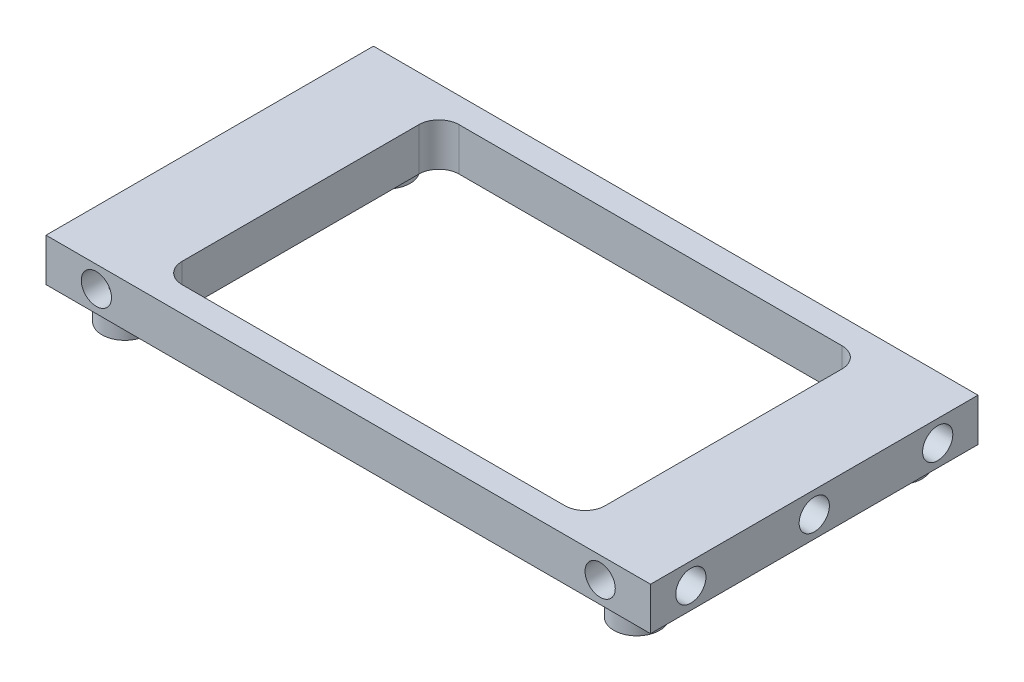
from build123d import *

# Parameters (mm, degrees)
SKETCH1_W                      = 65
SKETCH1_H                      = 8.5
BOSS_EXTRUDE1_DEPTH            = 120
F_6_0MM_DOWEL_HOLE1_AT_2_COUNT = 2
F_6_0MM_DOWEL_HOLE1_AT_2_PITCH = 24.5
F_6_0MM_DOWEL_HOLE1_AT_3_COUNT = 2
F_6_0MM_DOWEL_HOLE1_AT_3_PITCH = 49
F_6_0MM_DOWEL_HOLE2_AT_2_COUNT = 2
F_6_0MM_DOWEL_HOLE2_AT_2_PITCH = 100
CUT_EXTRUDE1_DEPTH             = 9.5
F_3_0MM_DOWEL_HOLE1_D          = 3.5
CUT_EXTRUDE2_DEPTH             = 9.5
FILLET1_R                      = 6
BOSS_EXTRUDE2_DEPTH            = 5
SKETCH12_R                     = 2.55
CUT_EXTRUDE3_DEPTH             = 1.7
CHAMFER1_SIZE                  = 1.5
SKETCH13_W                     = 84
SKETCH13_H                     = 55
CUT_EXTRUDE4_DEPTH             = 9.5
FILLET2_R                      = 4


with BuildPart() as part:
    # Sketch1 → Boss-Extrude1 (new body)
    with BuildSketch(Plane(origin=(0, 0, 0), x_dir=(0, 0, -1), z_dir=(1, 0, 0))):
        Rectangle(SKETCH1_W, SKETCH1_H)
    extrude(amount=BOSS_EXTRUDE1_DEPTH)

    # Sketch3 → Ø6.0mm Dowel Hole1 (revolve, cut)
    with BuildSketch(Plane(origin=(120, 0, 24.5), x_dir=(0, 0, -1), z_dir=(0, 1, 0))):
        Polygon((0, 0), (0, 11.802582), (3, 10), (3, 0), align=None)
    f_6_0mm_dowel_hole1 = revolve(axis=Axis((126.35, 0, 24.5), (-1, 0, 0)), mode=Mode.SUBTRACT)

    # Ø6.0mm Dowel Hole1 at 2: Ø6.0mm Dowel Hole1 ×2
    with Locations(*[(0, 0, -i * F_6_0MM_DOWEL_HOLE1_AT_2_PITCH) for i in range(1, F_6_0MM_DOWEL_HOLE1_AT_2_COUNT)]):
        add(f_6_0mm_dowel_hole1, mode=Mode.SUBTRACT)

    # Ø6.0mm Dowel Hole1 at 3: Ø6.0mm Dowel Hole1 ×2
    with Locations(*[(0, 0, -i * F_6_0MM_DOWEL_HOLE1_AT_3_PITCH) for i in range(1, F_6_0MM_DOWEL_HOLE1_AT_3_COUNT)]):
        add(f_6_0mm_dowel_hole1, mode=Mode.SUBTRACT)

    # Mirror1: Ø6.0mm Dowel Hole1 across plane
    add(f_6_0mm_dowel_hole1.mirror(Plane(origin=(60, 0, 0), x_dir=(0, 0, 1), z_dir=(1, 0, 0))), mode=Mode.SUBTRACT)

    # Mirror1 copy 1 sketch → Mirror1 copy 1 (revolve, cut)
    with BuildSketch(Plane(origin=(0, 0, 0), x_dir=(0, 0, -1), z_dir=(0, 1, 0))):
        Polygon((0, 0), (0, -11.802582), (3, -10), (3, 0), align=None)
    revolve(axis=Axis((-6.35, 0, 0), (-1, 0, 0)), mode=Mode.SUBTRACT)

    # Mirror1 copy 2 sketch → Mirror1 copy 2 (revolve, cut)
    with BuildSketch(Plane(origin=(0, 0, -24.5), x_dir=(0, 0, -1), z_dir=(0, 1, 0))):
        Polygon((0, 0), (0, -11.802582), (3, -10), (3, 0), align=None)
    revolve(axis=Axis((-6.35, 0, -24.5), (-1, 0, 0)), mode=Mode.SUBTRACT)

    # Sketch5 → Ø6.0mm Dowel Hole2 (revolve, cut)
    with BuildSketch(Plane(origin=(110, 0, -32.5), x_dir=(0, 1, 0), z_dir=(1, 0, 0))):
        Polygon((0, 0), (0, 9.802582), (3, 8), (3, 0), align=None)
    f_6_0mm_dowel_hole2 = revolve(axis=Axis((110, 0, -38.85), (0, 0, 1)), mode=Mode.SUBTRACT)

    # Ø6.0mm Dowel Hole2 at 2: Ø6.0mm Dowel Hole2 ×2
    with Locations(*[(-i * F_6_0MM_DOWEL_HOLE2_AT_2_PITCH, 0, 0) for i in range(1, F_6_0MM_DOWEL_HOLE2_AT_2_COUNT)]):
        add(f_6_0mm_dowel_hole2, mode=Mode.SUBTRACT)

    # Mirror2: Ø6.0mm Dowel Hole2 across plane
    add(f_6_0mm_dowel_hole2.mirror(Plane.XY), mode=Mode.SUBTRACT)

    # Mirror2 copy 1 sketch → Mirror2 copy 1 (revolve, cut)
    with BuildSketch(Plane(origin=(10, 0, 32.5), x_dir=(0, 1, 0), z_dir=(1, 0, 0))):
        Polygon((0, 0), (0, -9.802582), (3, -8), (3, 0), align=None)
    revolve(axis=Axis((10, 0, 38.85), (0, 0, 1)), mode=Mode.SUBTRACT)

    # Sketch6 → Cut-Extrude1 (cut, through all)
    with BuildSketch(Plane(origin=(0, 4.25, 0), x_dir=(1, 0, 0), z_dir=(0, 1, 0))):
        with BuildLine():
            Line((80, -7), (80, 7))
            ThreePointArc((80, 7), (86, 13), (92, 7))
            Line((92, 7), (92, -7))
            ThreePointArc((92, -7), (86, -13), (80, -7))
        make_face()
    cut_extrude1 = extrude(amount=-CUT_EXTRUDE1_DEPTH, mode=Mode.SUBTRACT)

    # Mirror3: Cut-Extrude1 across plane
    add(cut_extrude1.mirror(Plane(origin=(60, 0, 0), x_dir=(0, 0, 1), z_dir=(1, 0, 0))), mode=Mode.SUBTRACT)

    # Ø3.0mm Dowel Hole1 (through all)
    with Locations(Plane(origin=(0, 4.25, 0), x_dir=(1, 0, 0), z_dir=(0, 1, 0))):
        with Locations((87, -17), (87, 17), (33, 17), (33, -17), (100, -24.5), (60, -24.5), (20, -24.5), (100, 24.5), (60, 24.5), (20, 24.5)):
            Hole(F_3_0MM_DOWEL_HOLE1_D / 2)

    # Sketch10 → Cut-Extrude2 (cut, through all)
    with BuildSketch(Plane.XZ.offset(4.25)):
        with BuildLine():
            ThreePointArc((34, 13), (38.242641, 11.242641), (40, 7))
            Line((40, 7), (40, 21.5))
            Line((40, 21.5), (34, 13))
        make_face()
        Polygon((40, -7), (40, -21.5), (80, -21.5), (80, -7), (80, 7), (80, 21.5), (40, 21.5), (40, 7), align=None)
        with BuildLine():
            Line((34, -13), (40, -21.5))
            Line((40, -21.5), (40, -7))
            ThreePointArc((40, -7), (38.242641, -11.242641), (34, -13))
        make_face()
        with BuildLine():
            Line((80, 21.5), (80, 7))
            ThreePointArc((80, 7), (81.757359, 11.242641), (86, 13))
            Line((86, 13), (80, 21.5))
        make_face()
        with BuildLine():
            Line((80, -7), (80, -21.5))
            Line((80, -21.5), (86, -13))
            ThreePointArc((86, -13), (81.757359, -11.242641), (80, -7))
        make_face()
    extrude(amount=-CUT_EXTRUDE2_DEPTH, mode=Mode.SUBTRACT)

    # Fillet1
    fillet1_edges = [part.edges().sort_by_distance(p)[0] for p in [
        (34, 0, 13),
        (40, 0, 21.5),
        (80, 0, 21.5),
        (86, 0, 13),
        (86, 0, -13),
        (80, 0, -21.5),
        (40, 0, -21.5),
        (34, 0, -13),
    ]]
    fillet(fillet1_edges, radius=FILLET1_R)

    # Sketch11 → Boss-Extrude2 (add)
    with BuildSketch(Plane.XZ.offset(4.25)):
        with BuildLine():
            ThreePointArc((9.2, -21.485), (5.982664, -29.252336), (13.75, -26.035))
            Line((13.75, -26.035), (11.75, -26.035))
            ThreePointArc((11.75, -26.035), (7.396878, -27.838122), (9.2, -23.485))
            Line((9.2, -23.485), (9.2, -21.485))
        make_face()
        with BuildLine():
            Line((11.75, -26.035), (13.75, -26.035))
            ThreePointArc((13.75, -26.035), (12.417336, -22.817664), (9.2, -21.485))
            Line((9.2, -21.485), (9.2, -23.485))
            ThreePointArc((9.2, -23.485), (11.003122, -24.231878), (11.75, -26.035))
        make_face()
        with BuildLine():
            ThreePointArc((13.75, 26.035), (5.982664, 29.252336), (9.2, 21.485))
            Line((9.2, 21.485), (9.2, 23.485))
            ThreePointArc((9.2, 23.485), (7.396878, 27.838122), (11.75, 26.035))
            Line((11.75, 26.035), (13.75, 26.035))
        make_face()
        with BuildLine():
            Line((9.2, 23.485), (9.2, 21.485))
            ThreePointArc((9.2, 21.485), (12.417336, 22.817664), (13.75, 26.035))
            Line((13.75, 26.035), (11.75, 26.035))
            ThreePointArc((11.75, 26.035), (11.003122, 24.231878), (9.2, 23.485))
        make_face()
        with BuildLine():
            ThreePointArc((106.25, 26.035), (107.582664, 22.817664), (110.8, 21.485))
            Line((110.8, 21.485), (110.8, 23.485))
            ThreePointArc((110.8, 23.485), (108.996878, 24.231878), (108.25, 26.035))
            Line((108.25, 26.035), (106.25, 26.035))
        make_face()
        with BuildLine():
            Line((110.8, 23.485), (110.8, 21.485))
            ThreePointArc((110.8, 21.485), (114.017336, 22.817664), (115.35, 26.035))
            ThreePointArc((115.35, 26.035), (110.8, 30.585), (106.25, 26.035))
            Line((106.25, 26.035), (108.25, 26.035))
            ThreePointArc((108.25, 26.035), (110.8, 28.585), (113.35, 26.035))
            ThreePointArc((113.35, 26.035), (112.603122, 24.231878), (110.8, 23.485))
        make_face()
        with BuildLine():
            ThreePointArc((110.8, -21.485), (107.582664, -22.817664), (106.25, -26.035))
            Line((106.25, -26.035), (108.25, -26.035))
            ThreePointArc((108.25, -26.035), (108.996878, -24.231878), (110.8, -23.485))
            Line((110.8, -23.485), (110.8, -21.485))
        make_face()
        with BuildLine():
            Line((108.25, -26.035), (106.25, -26.035))
            ThreePointArc((106.25, -26.035), (110.8, -30.585), (115.35, -26.035))
            ThreePointArc((115.35, -26.035), (114.017336, -22.817664), (110.8, -21.485))
            Line((110.8, -21.485), (110.8, -23.485))
            ThreePointArc((110.8, -23.485), (112.603122, -24.231878), (113.35, -26.035))
            ThreePointArc((113.35, -26.035), (110.8, -28.585), (108.25, -26.035))
        make_face()
    extrude(amount=BOSS_EXTRUDE2_DEPTH)

    # Sketch12 → Cut-Extrude3 (cut)
    with BuildSketch(Plane.XZ.offset(4.25)):
        with Locations((110.8, -26.035)):
            Circle(SKETCH12_R)
        with Locations((110.8, 26.035)):
            Circle(SKETCH12_R)
        with Locations((9.2, 26.035)):
            Circle(SKETCH12_R)
        with Locations((9.2, -26.035)):
            Circle(SKETCH12_R)
    extrude(amount=-CUT_EXTRUDE3_DEPTH, mode=Mode.SUBTRACT)

    # Chamfer1
    chamfer1_edges = [part.edges().sort_by_distance(p)[0] for p in [
        (4.65, -4.25, -26.035),
        (9.2, -4.25, 30.585),
        (115.35, -4.25, 26.035),
        (110.8, -4.25, -30.585),
    ]]
    chamfer(chamfer1_edges, length=CHAMFER1_SIZE)

    # Sketch13 → Cut-Extrude4 (cut, through all)
    with BuildSketch(Plane.XZ.offset(4.25)):
        with Locations((60, 0)):
            Rectangle(SKETCH13_W, SKETCH13_H)
    extrude(amount=-CUT_EXTRUDE4_DEPTH, mode=Mode.SUBTRACT)

    # Fillet2
    fillet2_edges = [part.edges().sort_by_distance(p)[0] for p in [
        (18, 0, -27.5),
        (18, 0, 27.5),
        (102, 0, 27.5),
        (102, 0, -27.5),
    ]]
    fillet(fillet2_edges, radius=FILLET2_R)


solid = part.part
